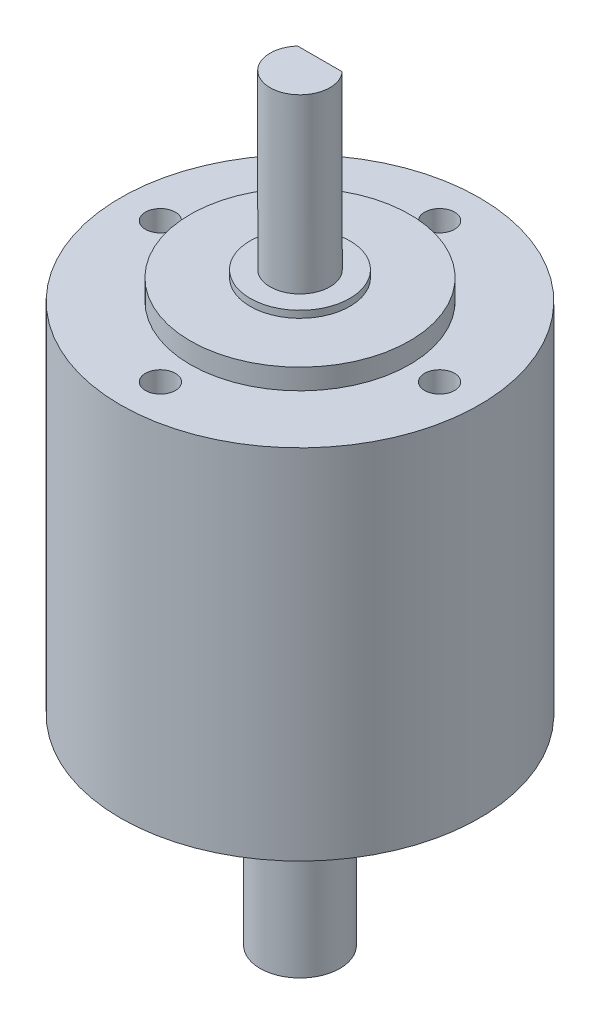
from build123d import *

# Parameters (mm, degrees)
SKETCH1_R           = 18
BOSS_EXTRUDE1_DEPTH = 17.9451
BOSS_EXTRUDE2_START = -17.9451
SKETCH2_R           = 11
BOSS_EXTRUDE2_DEPTH = 20.0025
SKETCH3_R           = 3
BOSS_EXTRUDE4_DEPTH = 18
CUT_EXTRUDE1_DEPTH  = 15
SKETCH5_R           = 1.5
CUT_EXTRUDE2_DEPTH  = 4
SKETCH6_R           = 4
BOSS_EXTRUDE5_DEPTH = 18
CUT_EXTRUDE3_DEPTH  = 15
SKETCH9_R           = 5
BOSS_EXTRUDE6_DEPTH = 20.701


with BuildPart() as part:
    # Sketch1 → Boss-Extrude1 (new body, symmetric)
    with BuildSketch(Plane(origin=(0, 0, 0), x_dir=(1, 0, 0), z_dir=(0, 1, 0))):
        Circle(SKETCH1_R)
    extrude(amount=BOSS_EXTRUDE1_DEPTH, both=True)

    # Sketch2 → Boss-Extrude2 (add, symmetric)
    with BuildSketch(Plane(origin=(0, 17.9451, 0), x_dir=(1, 0, 0), z_dir=(0, 1, 0)).offset(BOSS_EXTRUDE2_START)):
        Circle(SKETCH2_R)
    extrude(amount=BOSS_EXTRUDE2_DEPTH, both=True)

    # Sketch3 → Boss-Extrude4 (add)
    with BuildSketch(Plane(origin=(0, 20.0025, 0), x_dir=(1, 0, 0), z_dir=(0, 1, 0))):
        Circle(SKETCH3_R)
    extrude(amount=BOSS_EXTRUDE4_DEPTH)

    # Sketch4 → Cut-Extrude1 (cut)
    with BuildSketch(Plane(origin=(0, 38.0025, 0), x_dir=(1, 0, 0), z_dir=(0, 1, 0))):
        with BuildLine():
            Line((-2.236067977, 2), (2.236067977, 2))
            ThreePointArc((2.236067977, 2), (0, 3), (-2.236067977, 2))
        make_face()
    cut_extrude1 = extrude(amount=-CUT_EXTRUDE1_DEPTH, mode=Mode.SUBTRACT)

    # Sketch5 → Cut-Extrude2 (cut)
    with BuildSketch(Plane(origin=(0, 17.9451, 0), x_dir=(1, 0, 0), z_dir=(0, 1, 0))):
        with Locations((0, 14)):
            Circle(SKETCH5_R)
        with Locations((-14, 0)):
            Circle(SKETCH5_R)
        with Locations((0, -14)):
            Circle(SKETCH5_R)
        with Locations((14, 0)):
            Circle(SKETCH5_R)
    cut_extrude2 = extrude(amount=-CUT_EXTRUDE2_DEPTH, mode=Mode.SUBTRACT)

    # Mirror1: Cut-Extrude1, Cut-Extrude2 across plane
    add(cut_extrude1.mirror(Plane.ZX), mode=Mode.SUBTRACT)
    add(cut_extrude2.mirror(Plane.ZX), mode=Mode.SUBTRACT)

    # Sketch6 → Boss-Extrude5 (add)
    with BuildSketch(Plane.XZ.offset(20.0025)):
        Circle(SKETCH6_R)
    extrude(amount=BOSS_EXTRUDE5_DEPTH)

    # Sketch7 → Cut-Extrude3 (cut)
    with BuildSketch(Plane.XZ.offset(38.0025)):
        with BuildLine():
            Line((-2.645751311, -3), (2.645751311, -3))
            ThreePointArc((2.645751311, -3), (0, -4), (-2.645751311, -3))
        make_face()
    extrude(amount=-CUT_EXTRUDE3_DEPTH, mode=Mode.SUBTRACT)

    # Sketch9 → Boss-Extrude6 (add, symmetric)
    with BuildSketch(Plane(origin=(0, 0, 0), x_dir=(1, 0, 0), z_dir=(0, 1, 0))):
        Circle(SKETCH9_R)
    extrude(amount=BOSS_EXTRUDE6_DEPTH, both=True)


solid = part.part
